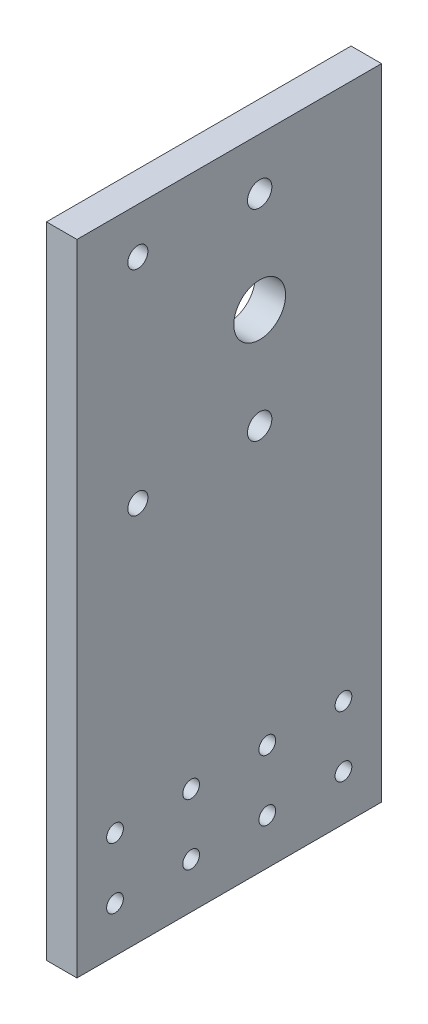
from build123d import *

# Parameters (mm, degrees)
SKETCH2_W                                            = 100
SKETCH2_H                                            = 210
SKETCH2_R                                            = 4
BOSS_EXTRUDE1_DEPTH                                  = 10
SKETCH3_R                                            = 2.5
MOUNT_DEPTH                                          = 11
SKETCH7_R                                            = 2.5
SUPPORT_PROFILE_MOUNT_DEPTH                          = 11
SKETCH5_R                                            = 8.5
BEARING_MOUNT_DEPTH                                  = 11
CSK_FOR_M6_SOCKET_COUNTERSUNK_HEAD_SCREW_D           = 6.6
CSK_FOR_M6_SOCKET_COUNTERSUNK_HEAD_SCREW_DEPTH       = 15
CSK_FOR_M6_SOCKET_COUNTERSUNK_HEAD_SCREW_CSINK_D     = 13.71
CSK_FOR_M6_SOCKET_COUNTERSUNK_HEAD_SCREW_CSINK_ANGLE = 90
CSK_FOR_M6_SOCKET_COUNTERSUNK_HEAD_SCREW_TIP         = 1.982840043
CSK_FOR_M5_SOCKET_COUNTERSUNK_HEAD_SCREW_D           = 5.5
CSK_FOR_M5_SOCKET_COUNTERSUNK_HEAD_SCREW_DEPTH       = 15
CSK_FOR_M5_SOCKET_COUNTERSUNK_HEAD_SCREW_CSINK_D     = 11.47
CSK_FOR_M5_SOCKET_COUNTERSUNK_HEAD_SCREW_CSINK_ANGLE = 90
CSK_FOR_M5_SOCKET_COUNTERSUNK_HEAD_SCREW_TIP         = 1.652366702


with BuildPart() as part:
    # Sketch2 → Boss-Extrude1 (new body)
    with BuildSketch(Plane(origin=(0, 0, 0), x_dir=(0, 0, -1), z_dir=(1, 0, 0))):
        with Locations((-10, 0)):
            Rectangle(SKETCH2_W, SKETCH2_H)
        with Locations((0, 88)):
            Circle(SKETCH2_R, mode=Mode.SUBTRACT)
        with Locations((0, 22)):
            Circle(SKETCH2_R, mode=Mode.SUBTRACT)
    extrude(amount=BOSS_EXTRUDE1_DEPTH)

    # Sketch3 → mount (cut, through all)
    with BuildSketch(Plane(origin=(10, 0, 0), x_dir=(0, 0, -1), z_dir=(1, 0, 0))):
        with Locations((-22.5, -70)):
            Circle(SKETCH3_R)
        with Locations((-47.5, -70)):
            Circle(SKETCH3_R)
        with Locations((-47.5, -90)):
            Circle(SKETCH3_R)
        with Locations((-22.5, -90)):
            Circle(SKETCH3_R)
        with Locations((2.5, -90)):
            Circle(SKETCH3_R)
        with Locations((27.5, -90)):
            Circle(SKETCH3_R)
        with Locations((27.5, -70)):
            Circle(SKETCH3_R)
        with Locations((2.5, -70)):
            Circle(SKETCH3_R)
    extrude(amount=-MOUNT_DEPTH, mode=Mode.SUBTRACT)

    # Sketch7 → support_profile_mount (cut, through all)
    with BuildSketch(Plane(origin=(10, 0, 0), x_dir=(0, 0, -1), z_dir=(1, 0, 0))):
        with Locations((-40, 90)):
            Circle(SKETCH7_R)
        with Locations((-40, 20)):
            Circle(SKETCH7_R)
    extrude(amount=-SUPPORT_PROFILE_MOUNT_DEPTH, mode=Mode.SUBTRACT)

    # Sketch5 → bearing_mount (cut, through all)
    with BuildSketch(Plane(origin=(10, 0, 0), x_dir=(0, 0, -1), z_dir=(1, 0, 0))):
        with Locations((0, 55)):
            Circle(SKETCH5_R)
    extrude(amount=-BEARING_MOUNT_DEPTH, mode=Mode.SUBTRACT)

    # CSK for M6 socket countersunk head screw
    with Locations(Plane.ZY):
        with Locations((40, 90), (40, 20)):
            CounterSinkHole(CSK_FOR_M6_SOCKET_COUNTERSUNK_HEAD_SCREW_D / 2, CSK_FOR_M6_SOCKET_COUNTERSUNK_HEAD_SCREW_CSINK_D / 2, depth=CSK_FOR_M6_SOCKET_COUNTERSUNK_HEAD_SCREW_DEPTH, counter_sink_angle=CSK_FOR_M6_SOCKET_COUNTERSUNK_HEAD_SCREW_CSINK_ANGLE)
            with Locations((0, 0, -(CSK_FOR_M6_SOCKET_COUNTERSUNK_HEAD_SCREW_DEPTH + CSK_FOR_M6_SOCKET_COUNTERSUNK_HEAD_SCREW_TIP / 2))):  # 118° drill point
                Cone(0, CSK_FOR_M6_SOCKET_COUNTERSUNK_HEAD_SCREW_D / 2, CSK_FOR_M6_SOCKET_COUNTERSUNK_HEAD_SCREW_TIP, mode=Mode.SUBTRACT)

    # CSK for M5 socket countersunk head screw
    with Locations(Plane.ZY):
        with Locations((-27.5, -70), (-2.5, -70), (22.5, -70), (47.5, -70), (47.5, -90), (22.5, -90), (-2.5, -90), (-27.5, -90)):
            CounterSinkHole(CSK_FOR_M5_SOCKET_COUNTERSUNK_HEAD_SCREW_D / 2, CSK_FOR_M5_SOCKET_COUNTERSUNK_HEAD_SCREW_CSINK_D / 2, depth=CSK_FOR_M5_SOCKET_COUNTERSUNK_HEAD_SCREW_DEPTH, counter_sink_angle=CSK_FOR_M5_SOCKET_COUNTERSUNK_HEAD_SCREW_CSINK_ANGLE)
            with Locations((0, 0, -(CSK_FOR_M5_SOCKET_COUNTERSUNK_HEAD_SCREW_DEPTH + CSK_FOR_M5_SOCKET_COUNTERSUNK_HEAD_SCREW_TIP / 2))):  # 118° drill point
                Cone(0, CSK_FOR_M5_SOCKET_COUNTERSUNK_HEAD_SCREW_D / 2, CSK_FOR_M5_SOCKET_COUNTERSUNK_HEAD_SCREW_TIP, mode=Mode.SUBTRACT)


solid = part.part
